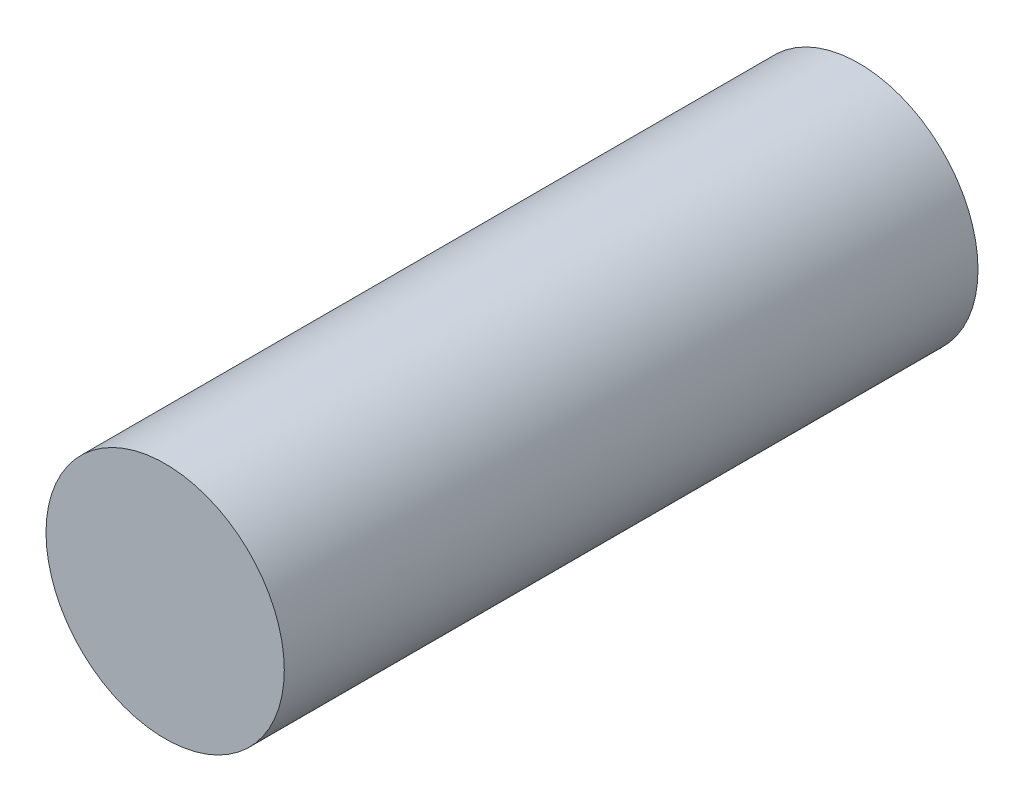
from build123d import *

# Parameters (mm, degrees)
SKETCH1_R           = 4.3625
BOSS_EXTRUDE1_DEPTH = 25.4


with BuildPart() as part:
    # Sketch1 → Boss-Extrude1 (new body)
    with BuildSketch(Plane.XY):
        with Locations((108.042890629, 14.636479869)):
            Circle(SKETCH1_R)
    extrude(amount=-BOSS_EXTRUDE1_DEPTH)


solid = part.part
